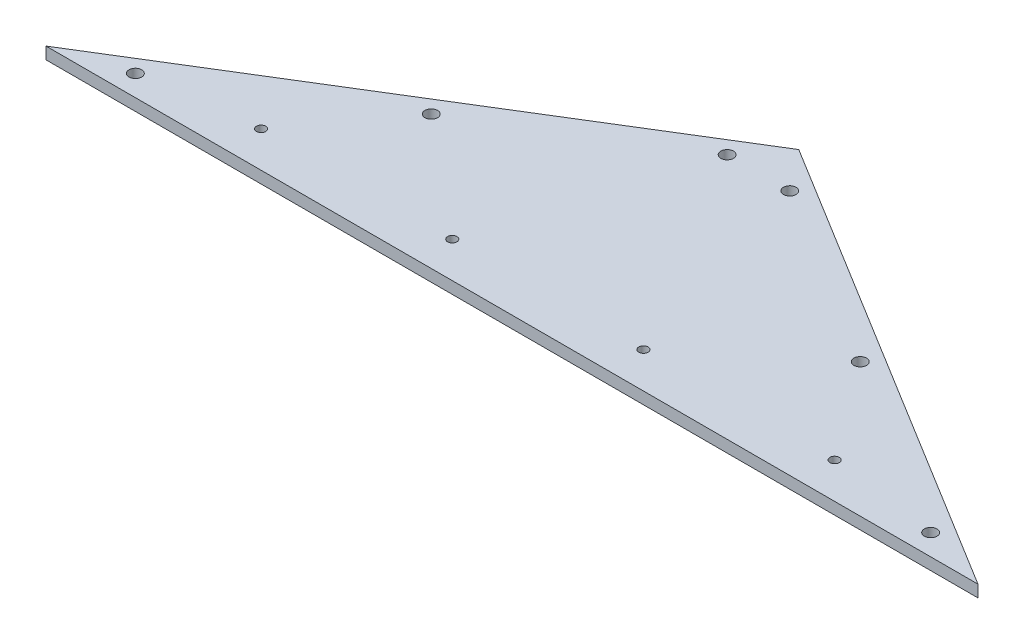
from build123d import *

# Parameters (mm, degrees)
BOSS_EXTRUDE1_DEPTH = 6.35
SKETCH2_R           = 2.4638
CUT_EXTRUDE1_DEPTH  = 7.35
LPATTERN1_COUNT     = 4
LPATTERN1_PITCH     = 101.6
SKETCH3_R           = 3.3655
CUT_EXTRUDE2_DEPTH  = 7.35


with BuildPart() as part:
    # Sketch1 → Boss-Extrude1 (new body)
    with BuildSketch(Plane(origin=(0, 0, 0), x_dir=(1, 0, 0), z_dir=(0, 1, 0))):
        Polygon((0, 0), (247.65, 152.4), (495.3, 0), align=None)
    extrude(amount=BOSS_EXTRUDE1_DEPTH)

    # Sketch2 → Cut-Extrude1 (cut, through all)
    with BuildSketch(Plane(origin=(0, 6.35, 0), x_dir=(1, 0, 0), z_dir=(0, 1, 0))):
        with Locations((95.25, 19.05)):
            Circle(SKETCH2_R)
    cut_extrude1 = extrude(amount=-CUT_EXTRUDE1_DEPTH, mode=Mode.SUBTRACT)

    # LPattern1: Cut-Extrude1 ×4
    with Locations(*[(i * LPATTERN1_PITCH, 0, 0) for i in range(1, LPATTERN1_COUNT)]):
        add(cut_extrude1, mode=Mode.SUBTRACT)

    # Sketch3 → Cut-Extrude2 (cut, through all)
    with BuildSketch(Plane(origin=(0, 6.35, 0), x_dir=(1, 0, 0), z_dir=(0, 1, 0))):
        with Locations((231.009906735, 130.975879922)):
            Circle(SKETCH3_R)
        with Locations((133.665361136, 71.071544168)):
            Circle(SKETCH3_R)
        with Locations((36.320815536, 11.167208415)):
            Circle(SKETCH3_R)
        with Locations((264.290093265, 130.975879922)):
            Circle(SKETCH3_R)
        with Locations((361.634638864, 71.071544168)):
            Circle(SKETCH3_R)
        with Locations((458.979184464, 11.167208415)):
            Circle(SKETCH3_R)
    extrude(amount=-CUT_EXTRUDE2_DEPTH, mode=Mode.SUBTRACT)


solid = part.part
